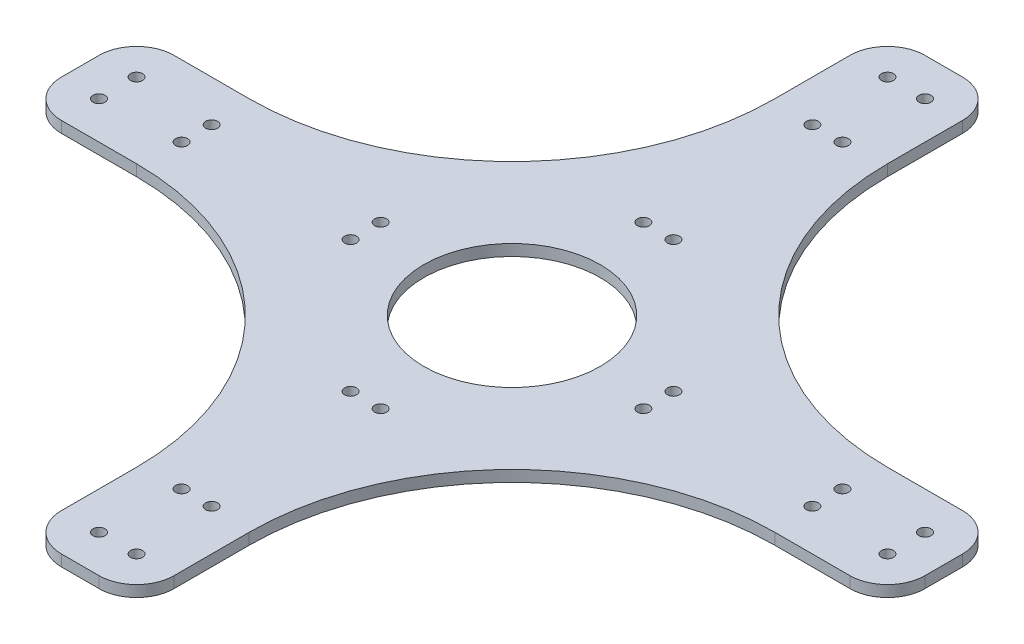
from build123d import *

# Parameters (mm, degrees)
BOSS_EXTRUDE1_DEPTH      = 1.5
M3_CLEARANCE_HOLE1_D     = 3.2
M3_CLEARANCE_HOLE1_DEPTH = 3
SKETCH5_R                = 23.5
CUT_EXTRUDE1_DEPTH       = 1
CUT_EXTRUDE1_DEPTH_BACK  = 4
SKETCH7_R                = 1.6
CUT_EXTRUDE2_DEPTH       = 4


with BuildPart() as part:
    # Sketch1 → Boss-Extrude1 (new body, symmetric)
    with BuildSketch(Plane(origin=(0, 0, 0), x_dir=(1, 0, 0), z_dir=(0, 1, 0))):
        with BuildLine():
            Line((85, 15), (105, 15))
            ThreePointArc((105, 15), (112.071067812, 12.071067812), (115, 5))
            Line((115, 5), (115, -5))
            ThreePointArc((115, -5), (112.071067812, -12.071067812), (105, -15))
            Line((105, -15), (85, -15))
            ThreePointArc((85, -15), (35.502525317, -35.502525317), (15, -85))
            Line((15, -85), (15, -105))
            ThreePointArc((15, -105), (12.071067812, -112.071067812), (5, -115))
            Line((5, -115), (-5, -115))
            ThreePointArc((-5, -115), (-12.071067812, -112.071067812), (-15, -105))
            Line((-15, -105), (-15, -85))
            ThreePointArc((-15, -85), (-35.502525317, -35.502525317), (-85, -15))
            Line((-85, -15), (-105, -15))
            ThreePointArc((-105, -15), (-112.071067812, -12.071067812), (-115, -5))
            Line((-115, -5), (-115, 5))
            ThreePointArc((-115, 5), (-112.071067812, 12.071067812), (-105, 15))
            Line((-105, 15), (-85, 15))
            ThreePointArc((-85, 15), (-35.502525317, 35.502525317), (-15, 85))
            Line((-15, 85), (-15, 105))
            ThreePointArc((-15, 105), (-12.071067812, 112.071067812), (-5, 115))
            Line((-5, 115), (5, 115))
            ThreePointArc((5, 115), (12.071067812, 112.071067812), (15, 105))
            Line((15, 105), (15, 85))
            ThreePointArc((15, 85), (35.502525317, 35.502525317), (85, 15))
        make_face()
    extrude(amount=BOSS_EXTRUDE1_DEPTH, both=True)

    # M3 Clearance Hole1
    with Locations(Plane(origin=(0, 1.5, 0), x_dir=(1, 0, 0), z_dir=(0, 1, 0))):
        with Locations((-105, 5), (-105, -5), (-5, 105), (5, 105), (105, 5), (105, -5), (5, -105), (-5, -105)):
            Hole(M3_CLEARANCE_HOLE1_D / 2, depth=M3_CLEARANCE_HOLE1_DEPTH)

    # Sketch5 → Cut-Extrude1 (cut, two sides)
    with BuildSketch(Plane(origin=(0, 1.5, 0), x_dir=(1, 0, 0), z_dir=(0, 1, 0))) as cut_extrude1_sk:
        Circle(SKETCH5_R)
    extrude(amount=CUT_EXTRUDE1_DEPTH, mode=Mode.SUBTRACT)
    extrude(cut_extrude1_sk.sketch, amount=-CUT_EXTRUDE1_DEPTH_BACK, mode=Mode.SUBTRACT)

    # Sketch7 → Cut-Extrude2 (cut, through all)
    with BuildSketch(Plane.XZ.offset(1.5)):
        with Locations((39, 4)):
            Circle(SKETCH7_R)
        with Locations((39, -4)):
            Circle(SKETCH7_R)
        with Locations((84, 4)):
            Circle(SKETCH7_R)
        with Locations((84, -4)):
            Circle(SKETCH7_R)
        with Locations((-4, -39)):
            Circle(SKETCH7_R)
        with Locations((4, -39)):
            Circle(SKETCH7_R)
        with Locations((4, -84)):
            Circle(SKETCH7_R)
        with Locations((-4, -84)):
            Circle(SKETCH7_R)
        with Locations((-39, 4)):
            Circle(SKETCH7_R)
        with Locations((-39, -4)):
            Circle(SKETCH7_R)
        with Locations((-84, -4)):
            Circle(SKETCH7_R)
        with Locations((-84, 4)):
            Circle(SKETCH7_R)
        with Locations((4, 39)):
            Circle(SKETCH7_R)
        with Locations((-4, 39)):
            Circle(SKETCH7_R)
        with Locations((-4, 84)):
            Circle(SKETCH7_R)
        with Locations((4, 84)):
            Circle(SKETCH7_R)
    extrude(amount=-CUT_EXTRUDE2_DEPTH, mode=Mode.SUBTRACT)


solid = part.part
